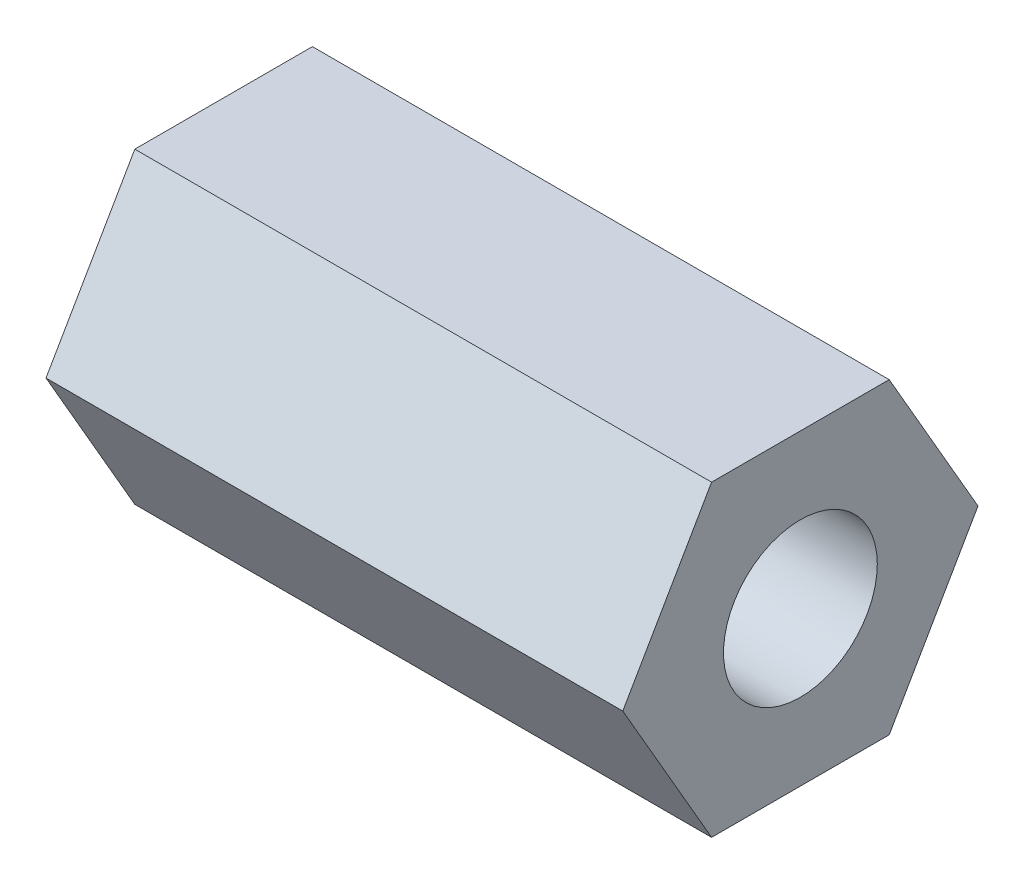
from build123d import *

# Parameters (mm, degrees)
SKETCH1_R           = 2
BOSS_EXTRUDE1_DEPTH = 15


with BuildPart() as part:
    # Sketch1 → Boss-Extrude1 (new body)
    with BuildSketch(Plane(origin=(0, 0, 0), x_dir=(0, 0, -1), z_dir=(1, 0, 0))):
        Polygon((2.309401077, -4), (4.618802154, 0), (2.309401077, 4), (-2.309401077, 4), (-4.618802154, 0), (-2.309401077, -4), align=None)
        Circle(SKETCH1_R, mode=Mode.SUBTRACT)
    extrude(amount=BOSS_EXTRUDE1_DEPTH)


solid = part.part
